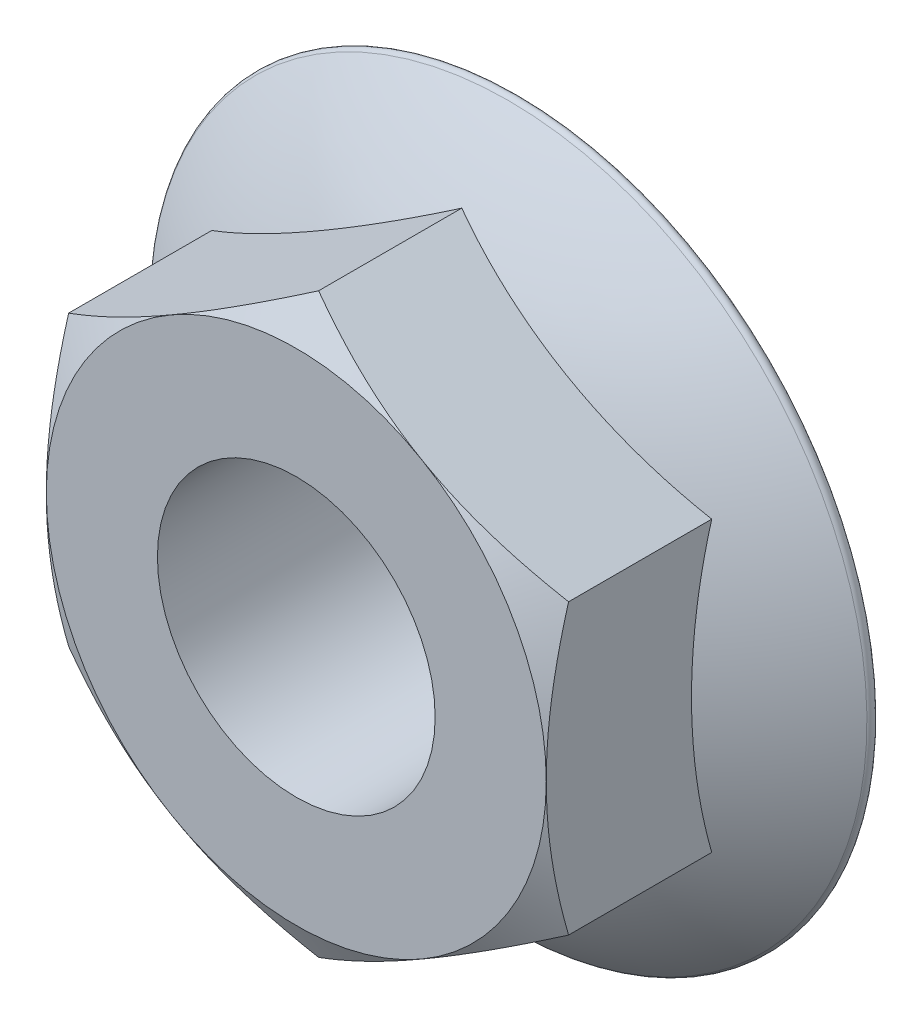
from build123d import *

# Parameters (mm, degrees)
EXTRUDE_1_DEPTH     = 20
SKETCH_3_OUTSIDE_W  = 154.97
SKETCH_3_OUTSIDE_H  = 154.97
SKETCH_3_OUTSIDE_R  = 22.5
CUT_EXTRUDE_2_DEPTH = 20
CUT_EXTRUDE_2_TAPER = 60
SKETCH_4_R          = 12.5
CUT_EXTRUDE_3_DEPTH = 21


with BuildPart() as part:
    # 草图1 → 凸台-拉伸1 (new body)
    with BuildSketch(Plane.XY):
        Polygon((22.5, -12.990381057), (22.5, 12.990381057), (0, 25.980762114), (-22.5, 12.990381057), (-22.5, -12.990381057), (0, -25.980762114), align=None)
    extrude(amount=EXTRUDE_1_DEPTH)

    # 草图2 → 旋转1 (revolve)
    with BuildSketch(Plane(origin=(0, 0, 0), x_dir=(0, 0, -1), z_dir=(1, 0, 0))):
        with BuildLine():
            Line((0, 0), (-12, 0))
            ThreePointArc((-12, 0), (-9.145772075, -17.058051419), (-0.894027207, -32.257802794))
            ThreePointArc((-0.894027207, -32.257802794), (-0.337232687, -32.42276506), (0, -31.95))
            Line((0, -31.95), (0, 0))
        make_face()
    revolve(axis=Axis((0, 0, 0), (0, 0, 1)))

    # 草图3 outside → 切除-拉伸2 (cut)
    with BuildSketch(Plane.XY.offset(20)):
        Rectangle(SKETCH_3_OUTSIDE_W, SKETCH_3_OUTSIDE_H)
        Circle(SKETCH_3_OUTSIDE_R, mode=Mode.SUBTRACT)
    extrude(amount=-CUT_EXTRUDE_2_DEPTH, taper=CUT_EXTRUDE_2_TAPER, mode=Mode.SUBTRACT)

    # 草图4 → 切除-拉伸3 (cut, through all)
    with BuildSketch(Plane.XY.offset(20)):
        Circle(SKETCH_4_R)
    extrude(amount=-CUT_EXTRUDE_3_DEPTH, mode=Mode.SUBTRACT)


solid = part.part
